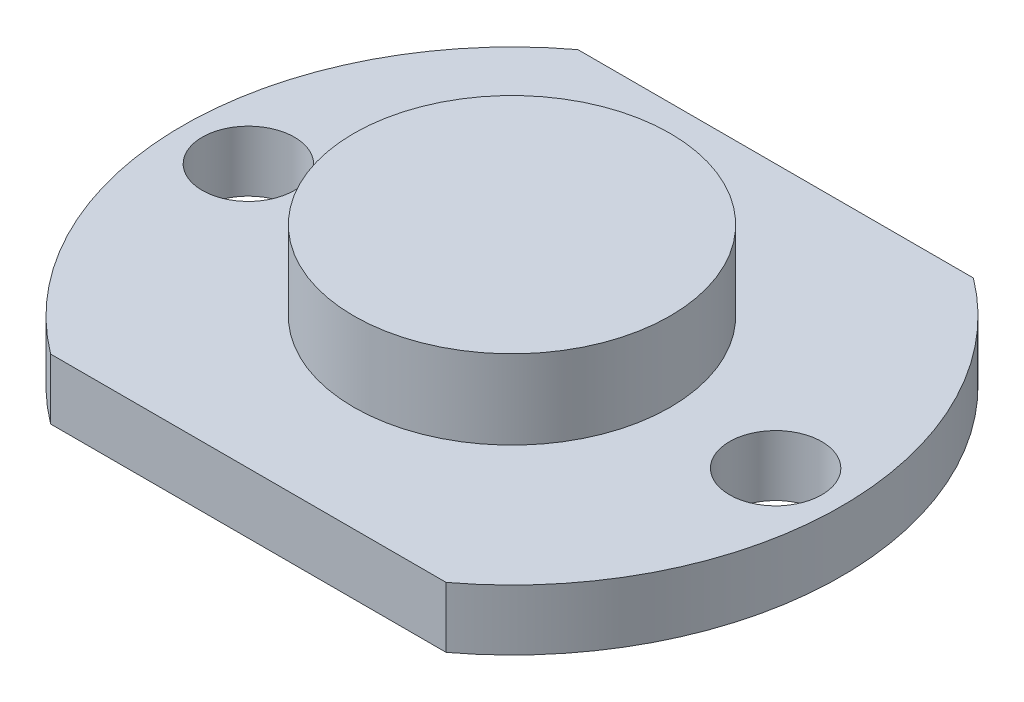
from build123d import *

# Parameters (mm, degrees)
SKETCH1_R           = 1.75
BOSS_EXTRUDE1_DEPTH = 2.3
SKETCH3_R           = 6
BOSS_EXTRUDE2_DEPTH = 3


with BuildPart() as part:
    # Sketch1 → Boss-Extrude1 (new body)
    with BuildSketch(Plane(origin=(0, 0, 0), x_dir=(1, 0, 0), z_dir=(0, 1, 0))):
        with BuildLine():
            Line((7.5, -10), (-7.5, -10))
            ThreePointArc((-7.5, -10), (-12.5, 0), (-7.5, 10))
            Line((-7.5, 10), (7.5, 10))
            ThreePointArc((7.5, 10), (12.5, 0), (7.5, -10))
        make_face()
        with Locations((10, 0)):
            Circle(SKETCH1_R, mode=Mode.SUBTRACT)
        with Locations((-10, 0)):
            Circle(SKETCH1_R, mode=Mode.SUBTRACT)
    extrude(amount=BOSS_EXTRUDE1_DEPTH)

    # Sketch3 → Boss-Extrude2 (add)
    with BuildSketch(Plane(origin=(0, 2.3, 0), x_dir=(1, 0, 0), z_dir=(0, 1, 0))):
        Circle(SKETCH3_R)
    extrude(amount=BOSS_EXTRUDE2_DEPTH)


solid = part.part
